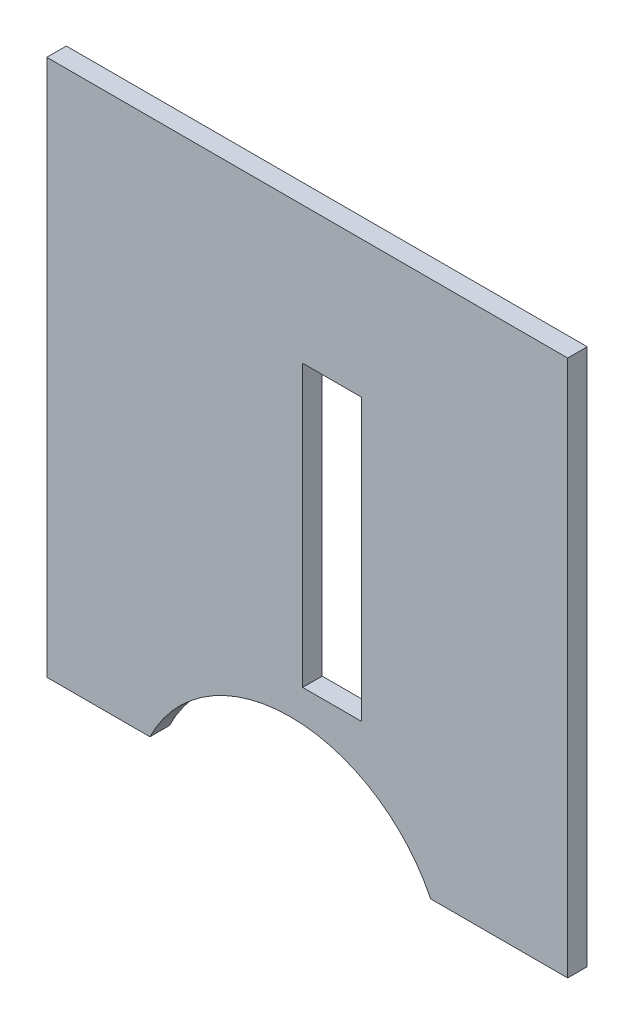
from build123d import *

# Parameters (mm, degrees)
SKETCH1_W           = 9
SKETCH1_H           = 43.113686922
BOSS_EXTRUDE1_DEPTH = 3


with BuildPart() as part:
    # Sketch1 → Boss-Extrude1 (new body)
    with BuildSketch(Plane.XY):
        with BuildLine():
            Line((0, -82.457009142), (15.843156539, -82.457009142))
            ThreePointArc((15.843156539, -82.457009142), (37.4, -69.007009142), (58.956843461, -82.457009142))
            Line((58.956843461, -82.457009142), (80, -82.457009142))
            Line((80, -82.457009142), (80, 0))
            Line((80, 0), (0, 0))
            Line((0, 0), (0, -82.457009142))
        make_face()
        with Locations((43.8, -42.6)):
            Rectangle(SKETCH1_W, SKETCH1_H, mode=Mode.SUBTRACT)
    extrude(amount=-BOSS_EXTRUDE1_DEPTH)


solid = part.part
